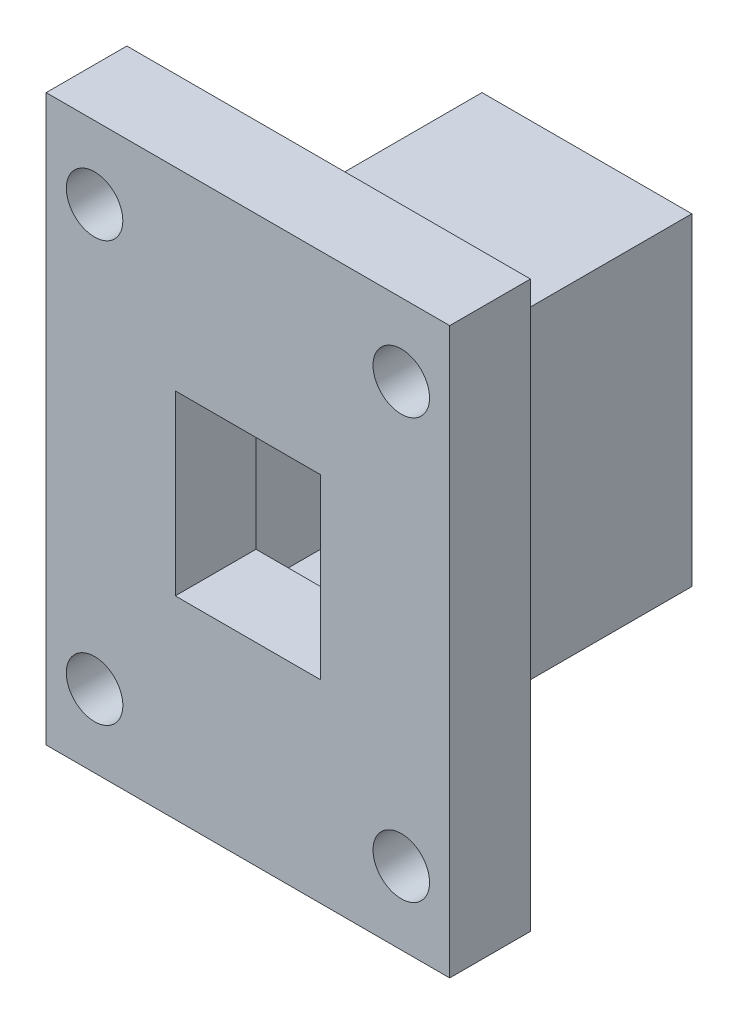
from build123d import *

# Parameters (mm, degrees)
SKETCH1_W           = 25
SKETCH1_H           = 35
BOSS_EXTRUDE1_DEPTH = 5
SKETCH2_W           = 9
SKETCH2_H           = 11
CUT_EXTRUDE1_DEPTH  = 6
SKETCH3_R           = 1.75
CUT_EXTRUDE2_DEPTH  = 6
SKETCH4_W           = 13
SKETCH4_H           = 20
SKETCH4_W_2         = 10
SKETCH4_H_2         = 16
BOSS_EXTRUDE2_DEPTH = 16


with BuildPart() as part:
    # Sketch1 → Boss-Extrude1 (new body)
    with BuildSketch(Plane.XY):
        with Locations((12.5, 17.5)):
            Rectangle(SKETCH1_W, SKETCH1_H)
    extrude(amount=BOSS_EXTRUDE1_DEPTH)

    # Sketch2 → Cut-Extrude1 (cut, through all)
    with BuildSketch(Plane.XY.offset(5)):
        with Locations((12.5, 17.5)):
            Rectangle(SKETCH2_W, SKETCH2_H)
    extrude(amount=-CUT_EXTRUDE1_DEPTH, mode=Mode.SUBTRACT)

    # Sketch3 → Cut-Extrude2 (cut, through all)
    with BuildSketch(Plane.XY.offset(5)):
        with Locations((3, 30.5)):
            Circle(SKETCH3_R)
        with Locations((3, 4.5)):
            Circle(SKETCH3_R)
        with Locations((22, 4.5)):
            Circle(SKETCH3_R)
        with Locations((22, 30.5)):
            Circle(SKETCH3_R)
    extrude(amount=-CUT_EXTRUDE2_DEPTH, mode=Mode.SUBTRACT)

    # Sketch4 → Boss-Extrude2 (add)
    with BuildSketch(Plane(origin=(0, 0, 0), x_dir=(-1, 0, 0), z_dir=(0, 0, -1))):
        with Locations((-12.5, 17.5)):
            Rectangle(SKETCH4_W, SKETCH4_H)
        with Locations((-12.5, 17.5)):
            Rectangle(SKETCH4_W_2, SKETCH4_H_2, mode=Mode.SUBTRACT)
    extrude(amount=BOSS_EXTRUDE2_DEPTH)


solid = part.part
